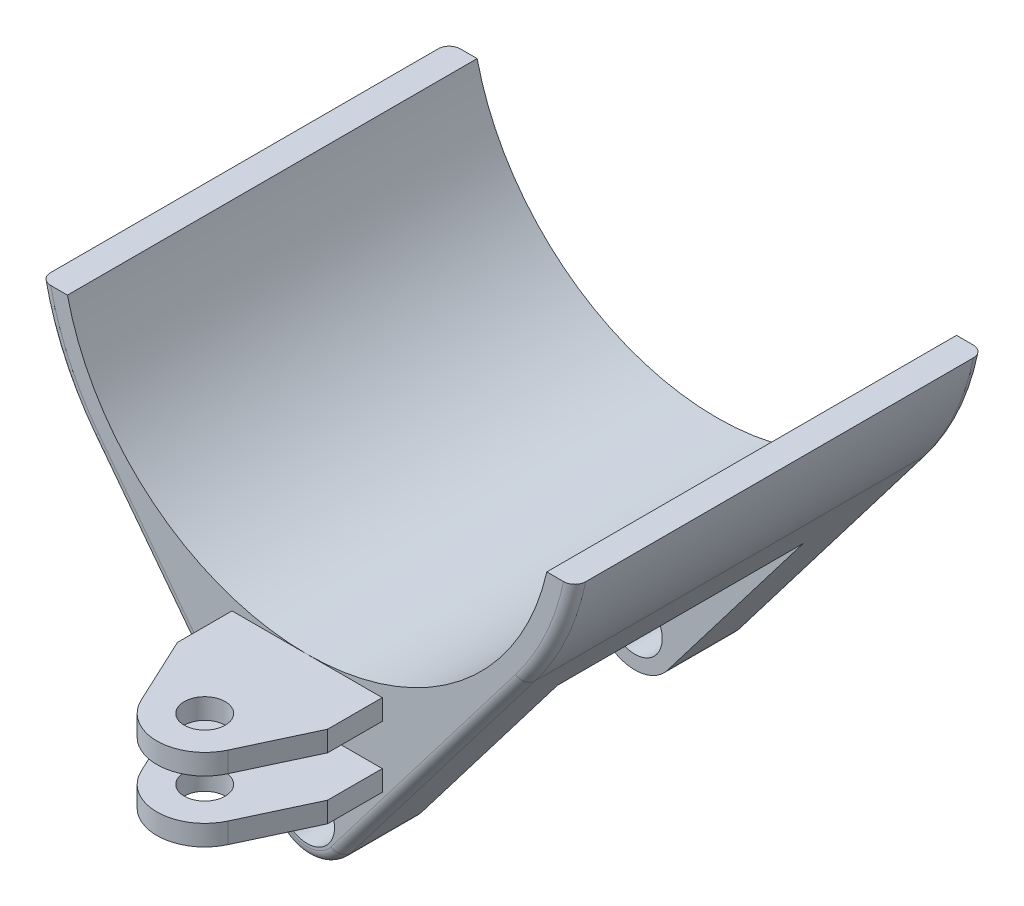
from build123d import *

# Parameters (mm, degrees)
SKETCH1_R               = 20
BOSS_EXTRUDE1_DEPTH     = 150
BOSS_EXTRUDE2_START     = 40
SKETCH2_R               = 15
BOSS_EXTRUDE2_DEPTH     = 60
SKETCH3_W               = 162.009512726
SKETCH3_H               = 30
CUT_EXTRUDE1_DEPTH      = 405.474968323
CUT_EXTRUDE1_DEPTH_BACK = 405.474968323
SKETCH4_W               = 180
SKETCH4_H               = 153.149018845
CUT_EXTRUDE2_DEPTH      = 405.474968323
CUT_EXTRUDE2_DEPTH_BACK = 405.474968323
CHAMFER1_SIZE           = 4
CHAMFER1_SIZE2          = 21.339042193
CHAMFER1_EDGE_2_SIZE    = 4
CHAMFER1_EDGE_2_SIZE2   = 21.339042193
FILLET1_R               = 4
FILLET2_R               = 8


with BuildPart() as part:
    # Sketch1 → Boss-Extrude1 (new, symmetric)
    with BuildSketch(Plane.XY):
        with BuildLine():
            Line((-195.959179423, 240), (-175.499287748, 240))
            ThreePointArc((-175.499287748, 240), (0, 100), (175.499287748, 240))
            Line((175.499287748, 240), (195.959179423, 240))
            ThreePointArc((195.959179423, 240), (182.049998135, 197.188176092), (158.918539009, 158.571428571))
            Line((158.918539009, 158.571428571), (23.837780851, -18.214285714))
            ThreePointArc((23.837780851, -18.214285714), (0, -30), (-23.837780851, -18.214285714))
            Line((-23.837780851, -18.214285714), (-158.918539009, 158.571428571))
            ThreePointArc((-158.918539009, 158.571428571), (-182.049998135, 197.188176092), (-195.959179423, 240))
        make_face()
        Circle(SKETCH1_R, mode=Mode.SUBTRACT)
    extrude(amount=BOSS_EXTRUDE1_DEPTH, both=True)

    # Sketch2 → Boss-Extrude2 (add)
    with BuildSketch(Plane(origin=(0, 0, 0), x_dir=(1, 0, 0), z_dir=(0, 1, 0)).offset(BOSS_EXTRUDE2_START)):
        with BuildLine():
            Line((-55, -150), (55, -150))
            Line((55, -150), (55, -190))
            Line((55, -190), (31.705882353, -239.823529412))
            ThreePointArc((31.705882353, -239.823529412), (0, -260), (-31.705882353, -239.823529412))
            Line((-31.705882353, -239.823529412), (-55, -190))
            Line((-55, -190), (-55, -150))
        make_face()
        with Locations(Location((0, -225, 0), (0, 0, 270))):
            Circle(SKETCH2_R, mode=Mode.SUBTRACT)
    extrude(amount=BOSS_EXTRUDE2_DEPTH)

    # Sketch3 → Cut-Extrude1 (cut, two sides)
    with BuildSketch(Plane(origin=(0, 0, 0), x_dir=(0, 0, -1), z_dir=(1, 0, 0))) as cut_extrude1_sk:
        with Locations((-231.004756363, 70)):
            Rectangle(SKETCH3_W, SKETCH3_H)
    extrude(amount=CUT_EXTRUDE1_DEPTH, mode=Mode.SUBTRACT)
    extrude(cut_extrude1_sk.sketch, amount=-CUT_EXTRUDE1_DEPTH_BACK, mode=Mode.SUBTRACT)

    # Sketch4 → Cut-Extrude2 (cut, two sides)
    with BuildSketch(Plane(origin=(0, 0, 0), x_dir=(0, 0, -1), z_dir=(1, 0, 0))) as cut_extrude2_sk:
        with Locations((0, 18.425490577)):
            Rectangle(SKETCH4_W, SKETCH4_H)
    extrude(amount=CUT_EXTRUDE2_DEPTH, mode=Mode.SUBTRACT)
    extrude(cut_extrude2_sk.sketch, amount=-CUT_EXTRUDE2_DEPTH_BACK, mode=Mode.SUBTRACT)

    # Chamfer1
    chamfer1_edges = [part.edges().sort_by_distance(p)[0] for p in [
        (110.344044156, 95, 0),
    ]]
    chamfer1_side = [part.faces().sort_by_distance(p)[0] for p in [
        (0, 95, 0),
    ]]
    chamfer(chamfer1_edges, length=CHAMFER1_SIZE, length2=CHAMFER1_SIZE2, reference=chamfer1_side[0])

    # Chamfer1 edge 2
    chamfer1_edge_2_edges = [part.edges().sort_by_distance(p)[0] for p in [
        (-110.344044156, 95, 0),
    ]]
    chamfer1_edge_2_side = [part.faces().sort_by_distance(p)[0] for p in [
        (0, 95, 0),
    ]]
    chamfer(chamfer1_edge_2_edges, length=CHAMFER1_EDGE_2_SIZE, length2=CHAMFER1_EDGE_2_SIZE2, reference=chamfer1_edge_2_side[0])

    # Fillet1
    fillet1_edges = [part.edges().sort_by_distance(p)[0] for p in [
        (0, 95, -90),
        (0, 95, 90),
    ]]
    fillet(fillet1_edges, radius=FILLET1_R)

    # Fillet2
    fillet2_edges = [part.edges().sort_by_distance(p)[0] for p in [
        (-91.37815993, 70.178571429, -150),
        (-182.049998135, 197.188176092, -150),
        (-182.049998135, 197.188176092, 150),
        (-91.37815993, 70.178571429, 150),
        (0, -30, 150),
        (91.37815993, 70.178571429, 150),
        (182.049998135, 197.188176092, 150),
        (182.049998135, 197.188176092, -150),
        (91.37815993, 70.178571429, -150),
        (0, -30, -150),
    ]]
    fillet(fillet2_edges, radius=FILLET2_R)


solid = part.part
